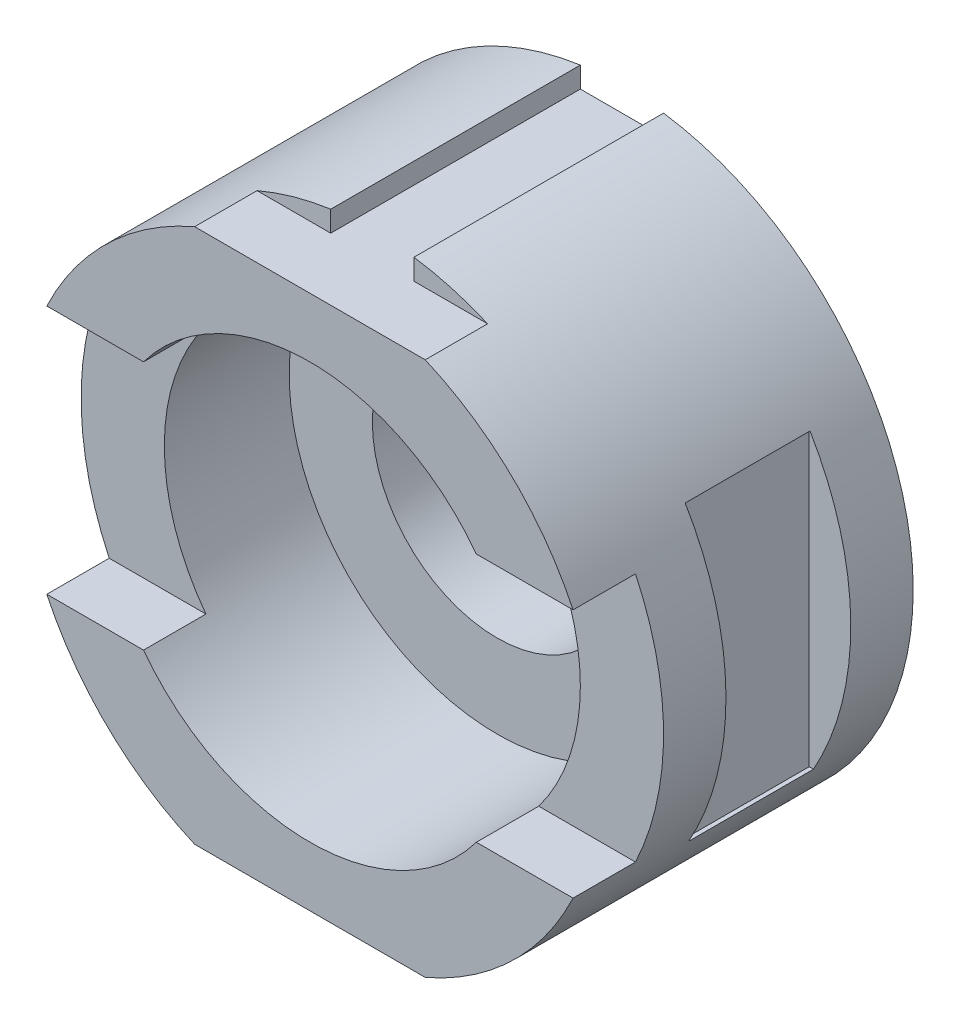
from build123d import *

# Parameters (mm, degrees)
SKETCH1_R           = 70
BOSS_EXTRUDE1_DEPTH = 75
SKETCH2_R           = 30
CUT_EXTRUDE1_DEPTH  = 75
CUT_EXTRUDE2_DEPTH  = 75
CUT_EXTRUDE3_DEPTH  = 75
SKETCH5_W           = 30
SKETCH5_H           = 70
CUT_EXTRUDE5_DEPTH  = 75
SKETCH6_W           = 30
SKETCH6_H           = 70
CUT_EXTRUDE6_DEPTH  = 75
SKETCH7_W           = 50
SKETCH7_H           = 15
CUT_EXTRUDE11_DEPTH = 5
CUT_EXTRUDE12_DEPTH = 88
SKETCH12_W          = 15
SKETCH12_H          = 1.10145185
CUT_EXTRUDE14_DEPTH = 88
SKETCH13_W          = 15
SKETCH13_H          = 1.10145185
CUT_EXTRUDE15_DEPTH = 88
SKETCH14_W          = 50
SKETCH14_H          = 15
CUT_EXTRUDE16_DEPTH = 5
SKETCH15_W          = 20
SKETCH15_H          = 5
CUT_EXTRUDE17_DEPTH = 73
SKETCH16_W          = 15
SKETCH16_H          = 1.10145185
CUT_EXTRUDE18_DEPTH = 73
SKETCH17_W          = 15
SKETCH17_H          = 1.10145185
CUT_EXTRUDE19_DEPTH = 73
CUT_EXTRUDE20_DEPTH = 15
SKETCH20_R          = 50
CUT_EXTRUDE21_DEPTH = 45


with BuildPart() as part:
    # Sketch1 → Boss-Extrude1 (new body)
    with BuildSketch(Plane.XY):
        Circle(SKETCH1_R)
    extrude(amount=BOSS_EXTRUDE1_DEPTH)

    # Sketch2 → Cut-Extrude1 (cut)
    with BuildSketch(Plane.XY.offset(75)):
        Circle(SKETCH2_R)
    extrude(amount=-CUT_EXTRUDE1_DEPTH, mode=Mode.SUBTRACT)

    # Sketch3 → Cut-Extrude2 (cut)
    with BuildSketch(Plane.XY.offset(75)):
        with BuildLine():
            Line((-10, 69.282032303), (10, 69.282032303))
            ThreePointArc((10, 69.282032303), (0, 70), (-10, 69.282032303))
        make_face()
    extrude(amount=-CUT_EXTRUDE2_DEPTH, mode=Mode.SUBTRACT)

    # Sketch4 → Cut-Extrude3 (cut)
    with BuildSketch(Plane.XY.offset(75)):
        with BuildLine():
            ThreePointArc((-10, -69.282032303), (0, -70), (10, -69.282032303))
            Line((10, -69.282032303), (-10, -69.282032303))
        make_face()
    extrude(amount=-CUT_EXTRUDE3_DEPTH, mode=Mode.SUBTRACT)

    # Sketch5 → Cut-Extrude5 (cut)
    with BuildSketch(Plane(origin=(-60, 0, 0), x_dir=(0, 0, -1), z_dir=(1, 0, 0))):
        with Locations((-30, 0.717967697)):
            Rectangle(SKETCH5_W, SKETCH5_H)
    extrude(amount=-CUT_EXTRUDE5_DEPTH, mode=Mode.SUBTRACT)

    # Sketch6 → Cut-Extrude6 (cut)
    with BuildSketch(Plane(origin=(60, 0, 0), x_dir=(0, 0, -1), z_dir=(1, 0, 0))):
        with Locations((-30, 0.717967697)):
            Rectangle(SKETCH6_W, SKETCH6_H)
    extrude(amount=CUT_EXTRUDE6_DEPTH, mode=Mode.SUBTRACT)

    # Sketch7 → Cut-Extrude11 (cut)
    with BuildSketch(Plane(origin=(0, 69.282032303, 0), x_dir=(1, 0, 0), z_dir=(0, 1, 0))):
        with Locations((0, -67.5)):
            Rectangle(SKETCH7_W, SKETCH7_H)
    extrude(amount=-CUT_EXTRUDE11_DEPTH, mode=Mode.SUBTRACT)

    # Sketch10 → Cut-Extrude12 (cut)
    with BuildSketch(Plane.XY.offset(60)):
        Polygon((-10, 69.282032303), (-10, 64.282032303), (10.07167941, 64.282032303), (10, 69.282032303), align=None)
    extrude(amount=-CUT_EXTRUDE12_DEPTH, mode=Mode.SUBTRACT)

    # Sketch12 → Cut-Extrude14 (cut)
    with BuildSketch(Plane(origin=(-25, 0, 0), x_dir=(0, 0, -1), z_dir=(1, 0, 0))):
        with Locations((-67.5, 64.832758228)):
            Rectangle(SKETCH12_W, SKETCH12_H)
    extrude(amount=-CUT_EXTRUDE14_DEPTH, mode=Mode.SUBTRACT)

    # Sketch13 → Cut-Extrude15 (cut)
    with BuildSketch(Plane.ZY.offset(-25)):
        with Locations((67.5, 64.832758228)):
            Rectangle(SKETCH13_W, SKETCH13_H)
    extrude(amount=-CUT_EXTRUDE15_DEPTH, mode=Mode.SUBTRACT)

    # Sketch14 → Cut-Extrude16 (cut)
    with BuildSketch(Plane.XZ.offset(69.282032303)):
        with Locations((0, 67.5)):
            Rectangle(SKETCH14_W, SKETCH14_H)
    extrude(amount=-CUT_EXTRUDE16_DEPTH, mode=Mode.SUBTRACT)

    # Sketch15 → Cut-Extrude17 (cut)
    with BuildSketch(Plane.XY.offset(60)):
        with Locations((0, -66.782032303)):
            Rectangle(SKETCH15_W, SKETCH15_H)
    extrude(amount=-CUT_EXTRUDE17_DEPTH, mode=Mode.SUBTRACT)

    # Sketch16 → Cut-Extrude18 (cut)
    with BuildSketch(Plane.ZY.offset(-25)):
        with Locations((67.5, -64.832758228)):
            Rectangle(SKETCH16_W, SKETCH16_H)
    extrude(amount=-CUT_EXTRUDE18_DEPTH, mode=Mode.SUBTRACT)

    # Sketch17 → Cut-Extrude19 (cut)
    with BuildSketch(Plane(origin=(-25, 0, 0), x_dir=(0, 0, -1), z_dir=(1, 0, 0))):
        with Locations((-67.5, -64.832758228)):
            Rectangle(SKETCH17_W, SKETCH17_H)
    extrude(amount=-CUT_EXTRUDE19_DEPTH, mode=Mode.SUBTRACT)

    # Sketch18 → Cut-Extrude20 (cut)
    with BuildSketch(Plane.XY.offset(75)):
        with BuildLine():
            ThreePointArc((0, -30), (-30, 0), (0, 30))
            Line((0, 30), (-63.245553203, 30))
            ThreePointArc((-63.245553203, 30), (-70, 0), (-63.245553203, -30))
            Line((-63.245553203, -30), (0, -30))
        make_face()
        with BuildLine():
            Line((63.245553203, 30), (0, 30))
            ThreePointArc((0, 30), (21.213203436, 21.213203436), (30, 0))
            ThreePointArc((30, 0), (21.213203436, -21.213203436), (0, -30))
            Line((0, -30), (63.245553203, -30))
            ThreePointArc((63.245553203, -30), (70, 0), (63.245553203, 30))
        make_face()
    extrude(amount=-CUT_EXTRUDE20_DEPTH, mode=Mode.SUBTRACT)

    # Sketch20 → Cut-Extrude21 (cut)
    with BuildSketch(Plane.XY.offset(75)):
        Circle(SKETCH20_R)
    extrude(amount=-CUT_EXTRUDE21_DEPTH, mode=Mode.SUBTRACT)


solid = part.part
